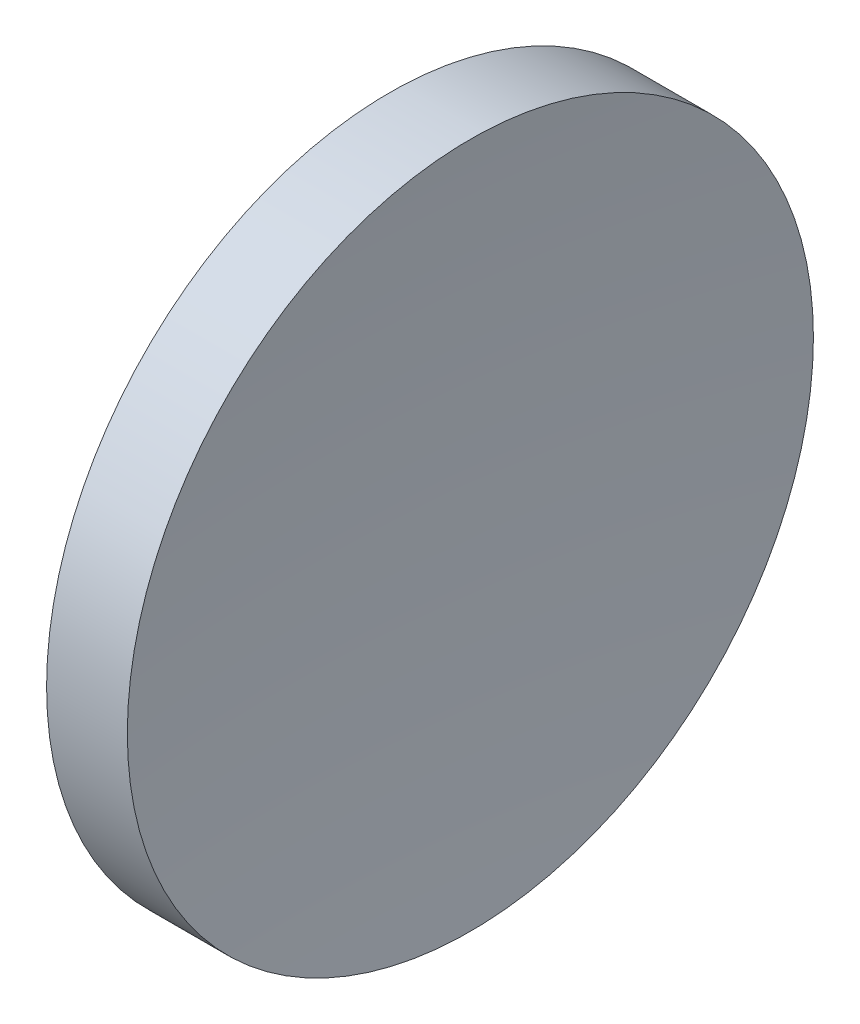
from build123d import *


with BuildPart() as part:
    # 草图1 → 旋转1 (revolve)
    with BuildSketch(Plane.XY, mode=Mode.PRIVATE) as revolve_1_sk:
        with BuildLine():
            Line((44.319152693, 26.089041149), (44.319152693, 34.089041149))
            Line((44.319152693, 34.089041149), (46.202074038, 34.089041149))
            ThreePointArc((46.202074038, 34.089041149), (45.91361665, 30.093683913), (45.819152693, 26.089041149))
            Line((45.819152693, 26.089041149), (44.319152693, 26.089041149))
        make_face()
    revolve(revolve_1_sk.sketch.rotate(Axis((42.449861114, 26.089041149, 0), (1, 0, 0)), 90), axis=Axis((42.449861114, 26.089041149, 0), (1, 0, 0)))  # turned: the seam where the file's is


solid = part.part
